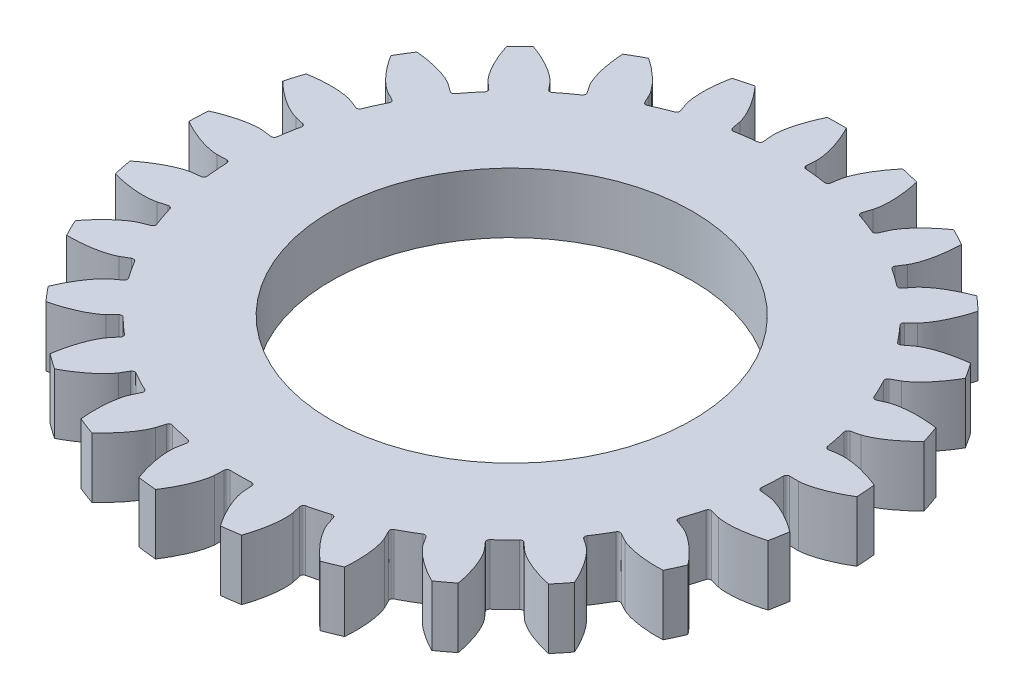
from build123d import *

# Parameters (mm, degrees)
SKETCH3_R               = 27.365
BOSS_EXTRUDE2_DEPTH     = 5
CUT_EXTRUDE1_DEPTH      = 5
FILLET1_R               = 0.253365
FILLET1_OF_MIRROR2_R    = 0.253365
CUT_EXTRUDE2_DEPTH      = 1.0000001
CUT_EXTRUDE2_DEPTH_BACK = 6.0000001
SKETCH6_R               = 15
CUT_EXTRUDE3_DEPTH      = 6.0000001


with BuildPart() as part:
    # Sketch3 → Boss-Extrude2 (new body)
    with BuildSketch(Plane(origin=(0, 0, 0), x_dir=(1, 0, 0), z_dir=(0, 1, 0))):
        Circle(SKETCH3_R)
    extrude(amount=-BOSS_EXTRUDE2_DEPTH)

    # Sketch4 → Cut-Extrude1 (cut)
    with BuildSketch(Plane(origin=(0, 0, 0), x_dir=(1, 0, 0), z_dir=(0, 1, 0))):
        with BuildLine():
            Line((23.808522087, 0), (22.80285, 0))
            ThreePointArc((22.80285, 0), (22.795921147, -0.5620918), (22.775138798, -1.123842007))
            Line((22.775138798, -1.123842007), (23.77958874, -1.173406713))
            ThreePointArc((23.77958874, -1.173406713), (23.801287651, -0.586881686), (23.808522087, 0))
        make_face()
        with BuildLine():
            add(Edge.make_bspline(
                [(23.808522087, 0), (23.826127738, 0), (23.875493591, 0.001153826), (23.968710388, 0.007885238), (24.12033093, 0.025327574), (24.400623176, 0.071497926), (24.734861734, 0.149847288), (25.0216111, 0.235022861), (25.248624765, 0.312256933), (25.334182097, 0.342709373)],
                knots=[0, 0, 0, 0, 0, 0.005376748, 0.015083688, 0.02853182, 0.046610139, 0.092110525, 0.119851432, 0.119851432, 0.119851432, 0.119851432, 0.119851432], degree=4))
            ThreePointArc((23.808522087, 0), (23.801287651, -0.586881686), (23.77958874, -1.173406713))
            Line((23.77958874, -1.173406713), (25.305709775, -1.248713342))
            ThreePointArc((25.305709775, -1.248713342), (25.328801274, -0.624546445), (25.3365, 0))
            ThreePointArc((25.3365, 0), (25.335920518, 0.171358606), (25.334182097, 0.342709373))
        make_face()
        with BuildLine():
            add(Edge.make_bspline(
                [(25.334182097, 0.342709373), (25.417426792, 0.372338675), (25.584260581, 0.434295585), (25.83262126, 0.533914927), (26.159196991, 0.67860072), (26.481919478, 0.83452889), (26.817171703, 1.009474652), (27.068710359, 1.150910221), (27.240106641, 1.251913602), (27.333700787, 1.308444232)],
                knots=[0.119851432, 0.119851432, 0.119851432, 0.119851432, 0.119851432, 0.146842495, 0.174208853, 0.201574955, 0.228941013, 0.256307345, 0.289707973, 0.289707973, 0.289707973, 0.289707973, 0.289707973], degree=4))
            ThreePointArc((25.334182097, 0.342709373), (25.335920518, 0.171358606), (25.3365, 0))
            ThreePointArc((25.3365, 0), (25.328801274, -0.624546445), (25.305709775, -1.248713342))
            Line((25.305709775, -1.248713342), (27.331744637, -1.348688279))
            ThreePointArc((27.331744637, -1.348688279), (27.364992584, -0.02014578), (27.333700787, 1.308444232))
        make_face()
    cut_extrude1 = extrude(amount=-CUT_EXTRUDE1_DEPTH, mode=Mode.SUBTRACT)

    # Fillet1
    fillet1_edges = [part.edges().sort_by_distance(p)[0] for p in [
        (22.80285, -2.5, 0),
    ]]
    fillet(fillet1_edges, radius=FILLET1_R)

    # Mirror2: Cut-Extrude1 across plane
    add(cut_extrude1.mirror(Plane(origin=(0, 0, 0), x_dir=(0.998784748, 0, 0.049285155), z_dir=(0.049285155, 0, -0.998784748))), mode=Mode.SUBTRACT)

    # Fillet1 of Mirror2
    fillet1_of_mirror2_edges = [part.edges().sort_by_distance(p)[0] for p in [
        (22.692072544, -2.5, 2.244952513),
    ]]
    fillet(fillet1_of_mirror2_edges, radius=FILLET1_OF_MIRROR2_R)

    # Sketch5 → Cut-Extrude2 (cut, two sides)
    with BuildSketch(Plane(origin=(0, 0, 0), x_dir=(1, 0, 0), z_dir=(0, 1, 0))) as cut_extrude2_sk:
        with BuildLine():
            ThreePointArc((-27.359092388, 0.568584829), (-27.28526113, -2.087522465), (-26.954174845, -4.723947863))
            add(Edge.make_bspline(
                [(-23.620784779, -2.983999059), (-23.638251604, -2.986205633), (-23.68708358, -2.993537543), (-23.778721665, -3.011899038), (-23.92696053, -3.048206929), (-24.199255908, -3.129143147), (-24.603939354, -3.279584024), (-25.037594793, -3.479346919), (-25.484225761, -3.720479602), (-25.867872687, -3.951866497), (-26.260239061, -4.206557346), (-26.568269996, -4.426083737), (-26.79812866, -4.600569009), (-26.954174845, -4.723947863)],
                knots=[0, 0, 0, 0, 0, 0.005376748, 0.015083688, 0.02853182, 0.046610139, 0.092110525, 0.146842495, 0.174208853, 0.201574955, 0.228941013, 0.289707973, 0.289707973, 0.289707973, 0.289707973, 0.289707973], degree=4))
            Line((-23.620784779, -2.983999059), (-22.873028678, -2.889535496))
            ThreePointArc((-22.873028678, -2.889535496), (-22.705442381, -2.79455521), (-22.653082813, -2.609177494))
            ThreePointArc((-22.653082813, -2.609177494), (-22.736404779, -1.739501613), (-22.78635133, -0.867272268))
            ThreePointArc((-22.78635133, -0.867272268), (-22.866301945, -0.692017251), (-23.046386572, -0.623636339))
            Line((-23.046386572, -0.623636339), (-23.799810021, -0.644024014))
            add(Edge.make_bspline(
                [(-23.799810021, -0.644024014), (-23.81740923, -0.644500249), (-23.86678823, -0.644682199), (-23.960153002, -0.640474778), (-24.112189881, -0.627140182), (-24.393628477, -0.588568672), (-24.816487668, -0.501440873), (-25.275484731, -0.369972436), (-25.753599653, -0.199589591), (-26.16798101, -0.02925771), (-26.594525428, 0.162780461), (-26.93236659, 0.332892903), (-27.186093453, 0.470380338), (-27.359092388, 0.568584829)],
                knots=[0, 0, 0, 0, 0, 0.005376748, 0.015083688, 0.02853182, 0.046610139, 0.092110525, 0.146842495, 0.174208853, 0.201574955, 0.228941013, 0.289707973, 0.289707973, 0.289707973, 0.289707973, 0.289707973], degree=4))
        make_face()
        with BuildLine():
            ThreePointArc((-26.358154894, 7.35465129), (-26.947190204, 4.763629404), (-27.282157938, 2.127694346))
            add(Edge.make_bspline(
                [(-23.620784779, 2.983999059), (-23.638251604, 2.986205633), (-23.687372806, 2.991248087), (-23.78069823, 2.996252917), (-23.933309303, 2.997951211), (-24.217178041, 2.98727486), (-24.646560737, 2.942201041), (-25.116271105, 2.856559786), (-25.608837599, 2.734075335), (-26.037975132, 2.605366996), (-26.481353633, 2.456255278), (-26.834301203, 2.32022989), (-27.100331158, 2.208389919), (-27.282157938, 2.127694346)],
                knots=[0, 0, 0, 0, 0, 0.005376748, 0.015083688, 0.02853182, 0.046610139, 0.092110525, 0.146842495, 0.174208853, 0.201574955, 0.228941013, 0.289707973, 0.289707973, 0.289707973, 0.289707973, 0.289707973], degree=4))
            Line((-23.620784779, 2.983999059), (-22.873028678, 2.889535496))
            ThreePointArc((-22.873028678, 2.889535496), (-22.687086776, 2.939854785), (-22.590270617, 3.106387224))
            ThreePointArc((-22.590270617, 3.106387224), (-22.454695273, 3.969461968), (-22.286158044, 4.826709826))
            ThreePointArc((-22.286158044, 4.826709826), (-22.320012713, 5.016341794), (-22.477434009, 5.12735962))
            Line((-22.477434009, 5.12735962), (-23.212257483, 5.294981254))
            add(Edge.make_bspline(
                [(-23.212257483, 5.294981254), (-23.229422216, 5.298896725), (-23.277295133, 5.31100055), (-23.366680336, 5.338294661), (-23.510624518, 5.389020361), (-23.773628858, 5.496371009), (-24.161535347, 5.685922332), (-24.573417304, 5.927408374), (-24.994138875, 6.211340675), (-25.353141864, 6.47937372), (-25.718527653, 6.771455942), (-26.00344967, 7.020241668), (-26.215013502, 7.216508988), (-26.358154894, 7.35465129)],
                knots=[0, 0, 0, 0, 0, 0.005376748, 0.015083688, 0.02853182, 0.046610139, 0.092110525, 0.146842495, 0.174208853, 0.201574955, 0.228941013, 0.289707973, 0.289707973, 0.289707973, 0.289707973, 0.289707973], degree=4))
        make_face()
        with BuildLine():
            add(Edge.make_bspline(
                [(-21.16619344, 10.901283375), (-21.181845172, 10.90934453), (-21.225203975, 10.932973602), (-21.304993208, 10.981639414), (-21.43180015, 11.066568935), (-21.659844705, 11.235953485), (-21.988424901, 11.516018126), (-22.327311692, 11.852348317), (-22.66420443, 12.231989562), (-22.945271572, 12.580882269), (-23.2265402, 12.954655942), (-23.440640373, 13.266482831), (-23.596747841, 13.509197837), (-23.701037589, 13.678597962)],
                knots=[0, 0, 0, 0, 0, 0.005376748, 0.015083688, 0.02853182, 0.046610139, 0.092110525, 0.146842495, 0.174208853, 0.201574955, 0.228941013, 0.289707973, 0.289707973, 0.289707973, 0.289707973, 0.289707973], degree=4))
            ThreePointArc((-23.701037589, 13.678597962), (-24.915928213, 11.315464918), (-25.895902711, 8.845645695))
            add(Edge.make_bspline(
                [(-22.136604, 8.764501543), (-22.152973321, 8.770982616), (-22.199297282, 8.788082598), (-22.288446065, 8.816139281), (-22.435840233, 8.855737051), (-22.713445812, 8.915991402), (-23.140548064, 8.979116794), (-23.616799731, 9.012978335), (-24.124351988, 9.016838263), (-24.572015839, 8.998895698), (-25.038547365, 8.964732348), (-25.414234576, 8.92075494), (-25.699720181, 8.878587587), (-25.895902711, 8.845645695)],
                knots=[0, 0, 0, 0, 0, 0.005376748, 0.015083688, 0.02853182, 0.046610139, 0.092110525, 0.146842495, 0.174208853, 0.201574955, 0.228941013, 0.289707973, 0.289707973, 0.289707973, 0.289707973, 0.289707973], degree=4))
            Line((-22.136604, 8.764501543), (-21.435832165, 8.487046346))
            ThreePointArc((-21.435832165, 8.487046346), (-21.243218071, 8.489542891), (-21.108028637, 8.626766208))
            ThreePointArc((-21.108028637, 8.626766208), (-20.762074681, 9.429009655), (-20.385643486, 10.217411991))
            ThreePointArc((-20.385643486, 10.217411991), (-20.371274996, 10.409505636), (-20.496141601, 10.556184716))
            Line((-20.496141601, 10.556184716), (-21.16619344, 10.901283375))
        make_face()
        with BuildLine():
            add(Edge.make_bspline(
                [(-17.790179618, 15.82261777), (-17.803334895, 15.834318097), (-17.83945519, 15.867987713), (-17.904635003, 15.934967375), (-18.006336959, 16.048764283), (-18.185092849, 16.26953968), (-18.433700851, 16.622520148), (-18.678298972, 17.032561625), (-18.910194667, 17.484057559), (-19.09566548, 17.891887716), (-19.275143805, 18.323867265), (-19.404969433, 18.679142087), (-19.495811731, 18.953054104), (-19.554696927, 19.143068017)],
                knots=[0, 0, 0, 0, 0, 0.005376748, 0.015083688, 0.02853182, 0.046610139, 0.092110525, 0.146842495, 0.174208853, 0.201574955, 0.228941013, 0.289707973, 0.289707973, 0.289707973, 0.289707973, 0.289707973], degree=4))
            ThreePointArc((-19.554696927, 19.143068017), (-21.319106817, 17.156308155), (-22.882512679, 15.007792593))
            add(Edge.make_bspline(
                [(-19.261498979, 13.994298161), (-19.27574225, 14.004646504), (-19.316358266, 14.032729559), (-19.395728864, 14.082075191), (-19.528644807, 14.157084363), (-19.782544249, 14.284483413), (-20.180529652, 14.451841615), (-20.633397974, 14.603078307), (-21.124044618, 14.733040082), (-21.56210642, 14.826990688), (-22.022477081, 14.909922316), (-22.397298124, 14.960756149), (-22.684301267, 14.990910943), (-22.882512679, 15.007792593)],
                knots=[0, 0, 0, 0, 0, 0.005376748, 0.015083688, 0.02853182, 0.046610139, 0.092110525, 0.146842495, 0.174208853, 0.201574955, 0.228941013, 0.289707973, 0.289707973, 0.289707973, 0.289707973, 0.289707973], degree=4))
            Line((-19.261498979, 13.994298161), (-18.651743482, 13.551284861))
            ThreePointArc((-18.651743482, 13.551284861), (-18.464559848, 13.505801795), (-18.299491587, 13.605093744))
            ThreePointArc((-18.299491587, 13.605093744), (-17.764896579, 14.296097987), (-17.204223974, 14.966116583))
            ThreePointArc((-17.204223974, 14.966116583), (-17.142535149, 15.148601954), (-17.227001237, 15.321725904))
            Line((-17.227001237, 15.321725904), (-17.790179618, 15.82261777))
        make_face()
        with BuildLine():
            add(Edge.make_bspline(
                [(-13.296343384, 19.749758899), (-13.306175611, 19.764363223), (-13.332787827, 19.805957798), (-13.379262731, 19.887042731), (-13.449469393, 20.022556748), (-13.56770473, 20.280850862), (-13.720719581, 20.684568095), (-13.855660035, 21.142556445), (-13.967987827, 21.637537918), (-14.046208497, 22.078680056), (-14.112619235, 22.541722617), (-14.150012897, 22.918122149), (-14.169882068, 23.206020276), (-14.179662739, 23.404708706)],
                knots=[0, 0, 0, 0, 0, 0.005376748, 0.015083688, 0.02853182, 0.046610139, 0.092110525, 0.146842495, 0.174208853, 0.201574955, 0.228941013, 0.289707973, 0.289707973, 0.289707973, 0.289707973, 0.289707973], degree=4))
            ThreePointArc((-14.179662739, 23.404708706), (-16.382727534, 21.919157455), (-18.431330218, 20.226944687))
            add(Edge.make_bspline(
                [(-15.176123138, 18.344781559), (-15.187345403, 18.358346946), (-15.21970142, 18.395648513), (-15.284306685, 18.463182526), (-15.394392807, 18.568889998), (-15.608632676, 18.755428796), (-15.952494343, 19.016504078), (-16.353523938, 19.275613163), (-16.796435837, 19.523510809), (-17.197370556, 19.723451324), (-17.622653568, 19.918267029), (-17.973057059, 20.060718027), (-18.243544279, 20.161300232), (-18.431330218, 20.226944687)],
                knots=[0, 0, 0, 0, 0, 0.005376748, 0.015083688, 0.02853182, 0.046610139, 0.092110525, 0.146842495, 0.174208853, 0.201574955, 0.228941013, 0.289707973, 0.289707973, 0.289707973, 0.289707973, 0.289707973], degree=4))
            Line((-15.176123138, 18.344781559), (-14.695697159, 17.76404631))
            ThreePointArc((-14.695697159, 17.76404631), (-14.525705422, 17.673441501), (-14.341130181, 17.728563204))
            ThreePointArc((-14.341130181, 17.728563204), (-13.65148469, 18.264909906), (-12.941799797, 18.774445028))
            ThreePointArc((-12.941799797, 18.774445028), (-12.836666774, 18.9358559), (-12.875425029, 19.124546704))
            Line((-12.875425029, 19.124546704), (-13.296343384, 19.749758899))
        make_face()
        with BuildLine():
            add(Edge.make_bspline(
                [(-7.967048994, 22.435950042), (-7.972940376, 22.452540719), (-7.98837237, 22.499446714), (-8.013222177, 22.589542053), (-8.047522202, 22.738258334), (-8.097807824, 23.017841597), (-8.145615039, 23.446928557), (-8.162419019, 23.924086686), (-8.148120941, 24.431452193), (-8.114176576, 24.878187728), (-8.063346896, 25.343198635), (-8.00595901, 25.717072309), (-7.953606603, 26.000866849), (-7.913668192, 26.19574547)],
                knots=[0, 0, 0, 0, 0, 0.005376748, 0.015083688, 0.02853182, 0.046610139, 0.092110525, 0.146842495, 0.174208853, 0.201574955, 0.228941013, 0.289707973, 0.289707973, 0.289707973, 0.289707973, 0.289707973], degree=4))
            ThreePointArc((-7.913668192, 26.19574547), (-10.416961228, 25.304745479), (-12.822039494, 24.175163458))
            add(Edge.make_bspline(
                [(-10.137175667, 21.542594863), (-10.144671789, 21.558524933), (-10.16673476, 21.602701217), (-10.212515305, 21.684180201), (-10.29285449, 21.813943984), (-10.453973307, 22.047901611), (-10.722105145, 22.386289652), (-11.046097849, 22.736990353), (-11.413445218, 23.087247548), (-11.752060652, 23.380614975), (-12.115533921, 23.675073771), (-12.419502719, 23.900191213), (-12.656478308, 24.064880879), (-12.822039494, 24.175163458)],
                knots=[0, 0, 0, 0, 0, 0.005376748, 0.015083688, 0.02853182, 0.046610139, 0.092110525, 0.146842495, 0.174208853, 0.201574955, 0.228941013, 0.289707973, 0.289707973, 0.289707973, 0.289707973, 0.289707973], degree=4))
            Line((-10.137175667, 21.542594863), (-9.816266137, 20.860627398))
            ThreePointArc((-9.816266137, 20.860627398), (-9.674147503, 20.73059388), (-9.481662822, 20.738081836))
            ThreePointArc((-9.481662822, 20.738081836), (-8.680299812, 21.086070362), (-7.866194743, 21.403106045))
            ThreePointArc((-7.866194743, 21.403106045), (-7.724223415, 21.533300378), (-7.714838513, 21.725701899))
            Line((-7.714838513, 21.725701899), (-7.967048994, 22.435950042))
        make_face()
        with BuildLine():
            add(Edge.make_bspline(
                [(-2.137155615, 23.71240793), (-2.138735974, 23.729942508), (-2.142018098, 23.779212645), (-2.143681402, 23.872657369), (-2.139919594, 24.025231525), (-2.119095871, 24.30853669), (-2.058691547, 24.736032265), (-1.956303198, 25.202378575), (-1.816277649, 25.690248473), (-1.672301099, 26.11450737), (-1.507424817, 26.552268277), (-1.358861276, 26.900124235), (-1.237576783, 27.161983333), (-1.150428768, 27.340807206)],
                knots=[0, 0, 0, 0, 0, 0.005376748, 0.015083688, 0.02853182, 0.046610139, 0.092110525, 0.146842495, 0.174208853, 0.201574955, 0.228941013, 0.289707973, 0.289707973, 0.289707973, 0.289707973, 0.289707973], degree=4))
            ThreePointArc((-1.150428768, 27.340807206), (-3.796658938, 27.10034328), (-6.407092873, 26.604367798))
            add(Edge.make_bspline(
                [(-4.461272167, 23.386807704), (-4.464571137, 23.404101511), (-4.474954764, 23.452376754), (-4.49903403, 23.542681084), (-4.544578271, 23.688347642), (-4.642452349, 23.95502368), (-4.818006648, 24.349462315), (-5.044604808, 24.769718819), (-5.313305861, 25.200327616), (-5.568325556, 25.568688599), (-5.847150719, 25.944288556), (-6.085585347, 26.237927487), (-6.274159258, 26.456376557), (-6.407092873, 26.604367798)],
                knots=[0, 0, 0, 0, 0, 0.005376748, 0.015083688, 0.02853182, 0.046610139, 0.092110525, 0.146842495, 0.174208853, 0.201574955, 0.228941013, 0.289707973, 0.289707973, 0.289707973, 0.289707973, 0.289707973], degree=4))
            Line((-4.461272167, 23.386807704), (-4.320043012, 22.646458546))
            ThreePointArc((-4.320043012, 22.646458546), (-4.214727317, 22.485166803), (-4.026427717, 22.444550518))
            ThreePointArc((-4.026427717, 22.444550518), (-3.163699772, 22.582315468), (-2.296327743, 22.686931194))
            ThreePointArc((-2.296327743, 22.686931194), (-2.126438692, 22.777728399), (-2.069500321, 22.961751343))
            Line((-2.069500321, 22.961751343), (-2.137155615, 23.71240793))
        make_face()
        with BuildLine():
            add(Edge.make_bspline(
                [(3.827023111, 23.498928019), (3.829853074, 23.516304736), (3.838927049, 23.564843192), (3.860554758, 23.655765825), (3.902142032, 23.802611059), (3.992766669, 24.071837023), (4.157587106, 24.470880094), (4.372734349, 24.897112329), (4.629689047, 25.33483196), (4.874651206, 25.709956472), (5.143214307, 26.092961251), (5.373618711, 26.392942423), (5.556214538, 26.61641251), (5.685096326, 26.767945472)],
                knots=[0, 0, 0, 0, 0, 0.005376748, 0.015083688, 0.02853182, 0.046610139, 0.092110525, 0.146842495, 0.174208853, 0.201574955, 0.228941013, 0.289707973, 0.289707973, 0.289707973, 0.289707973, 0.289707973], degree=4))
            ThreePointArc((5.685096326, 26.767945472), (3.062201397, 27.193126845), (0.410434957, 27.361921865))
            add(Edge.make_bspline(
                [(1.494949471, 23.761541407), (1.496054939, 23.779112317), (1.498003097, 23.828453208), (1.497138099, 23.921908731), (1.489250514, 24.074325299), (1.460770965, 24.356963512), (1.388824926, 24.782668711), (1.273859307, 25.246074754), (1.120688044, 25.729978418), (0.965287913, 26.150187483), (0.788630466, 26.583328276), (0.630711733, 26.92703828), (0.502388294, 27.185520795), (0.410434957, 27.361921865)],
                knots=[0, 0, 0, 0, 0, 0.005376748, 0.015083688, 0.02853182, 0.046610139, 0.092110525, 0.146842495, 0.174208853, 0.201574955, 0.228941013, 0.289707973, 0.289707973, 0.289707973, 0.289707973, 0.289707973], degree=4))
            Line((1.494949471, 23.761541407), (1.447624304, 23.009329416))
            ThreePointArc((1.447624304, 23.009329416), (1.509519687, 22.826914002), (1.68180265, 22.740745546))
            ThreePointArc((1.68180265, 22.740745546), (2.551687159, 22.65963064), (3.417825975, 22.54525302))
            ThreePointArc((3.417825975, 22.54525302), (3.604957995, 22.590947974), (3.705872188, 22.755029502))
            Line((3.705872188, 22.755029502), (3.827023111, 23.498928019))
        make_face()
        with BuildLine():
            add(Edge.make_bspline(
                [(9.5507359, 21.808924038), (9.557798368, 21.82505105), (9.578658291, 21.869807976), (9.622218065, 21.952495515), (9.699017723, 22.084385001), (9.853748995, 22.322615306), (10.112629272, 22.668132528), (10.427016914, 23.027468951), (10.784755354, 23.387534779), (11.115311249, 23.689954453), (11.470686361, 23.994137505), (11.768454471, 24.227394973), (12.000888465, 24.3984346), (12.16340591, 24.513155278)],
                knots=[0, 0, 0, 0, 0, 0.005376748, 0.015083688, 0.02853182, 0.046610139, 0.092110525, 0.146842495, 0.174208853, 0.201574955, 0.228941013, 0.289707973, 0.289707973, 0.289707973, 0.289707973, 0.289707973], degree=4))
            ThreePointArc((12.16340591, 24.513155278), (9.728652356, 25.577266241), (7.202173649, 26.400225751))
            add(Edge.make_bspline(
                [(7.357237936, 22.643250074), (7.362678381, 22.659994043), (7.376835915, 22.707300312), (7.399239536, 22.798034874), (7.429504213, 22.947624557), (7.472208666, 23.228465747), (7.508391523, 23.658688887), (7.512282156, 24.136126964), (7.484264998, 24.642920049), (7.438248793, 25.088573914), (7.3748591, 25.552039713), (7.307378876, 25.924224227), (7.247368941, 26.206498781), (7.202173649, 26.400225751)],
                knots=[0, 0, 0, 0, 0, 0.005376748, 0.015083688, 0.02853182, 0.046610139, 0.092110525, 0.146842495, 0.174208853, 0.201574955, 0.228941013, 0.289707973, 0.289707973, 0.289707973, 0.289707973, 0.289707973], degree=4))
            Line((7.357237936, 22.643250074), (7.124332061, 21.926439496))
            ThreePointArc((7.124332061, 21.926439496), (7.138918018, 21.734362242), (7.284359171, 21.608055896))
            ThreePointArc((7.284359171, 21.608055896), (8.106742202, 21.313157884), (8.917225117, 20.986973682))
            ThreePointArc((8.917225117, 20.986973682), (9.109841914, 20.984695205), (9.248391118, 21.11852547))
            Line((9.248391118, 21.11852547), (9.5507359, 21.808924038))
        make_face()
        with BuildLine():
            add(Edge.make_bspline(
                [(14.674340827, 18.748585153), (14.68519204, 18.76244914), (14.716527205, 18.800612293), (14.779282023, 18.869869176), (14.88646846, 18.978515813), (15.095584032, 19.170781572), (15.432257748, 19.441062829), (15.826131659, 19.710925009), (16.262175818, 19.970712776), (16.657555406, 20.181425471), (17.077413005, 20.387673857), (17.423834955, 20.539551194), (17.691502434, 20.647413313), (17.877443966, 20.718113385)],
                knots=[0, 0, 0, 0, 0, 0.005376748, 0.015083688, 0.02853182, 0.046610139, 0.092110525, 0.146842495, 0.174208853, 0.201574955, 0.228941013, 0.289707973, 0.289707973, 0.289707973, 0.289707973, 0.289707973], degree=4))
            ThreePointArc((17.877443966, 20.718113385), (15.783816307, 22.354291932), (13.541373283, 23.779706361))
            add(Edge.make_bspline(
                [(12.757244083, 20.102200063), (12.766677663, 20.117065006), (12.792155002, 20.159364225), (12.83641954, 20.24167664), (12.902934838, 20.37904017), (13.014140017, 20.640438052), (13.156178266, 21.04814663), (13.278680689, 21.50961755), (13.377578057, 22.007456383), (13.443837145, 22.450552977), (13.497698213, 22.915222521), (13.524896529, 23.292495824), (13.536970743, 23.580826067), (13.541373283, 23.779706361)],
                knots=[0, 0, 0, 0, 0, 0.005376748, 0.015083688, 0.02853182, 0.046610139, 0.092110525, 0.146842495, 0.174208853, 0.201574955, 0.228941013, 0.289707973, 0.289707973, 0.289707973, 0.289707973, 0.289707973], degree=4))
            Line((12.757244083, 20.102200063), (12.353391833, 19.465830743))
            ThreePointArc((12.353391833, 19.465830743), (12.319751874, 19.276160569), (12.429212615, 19.117652625))
            ThreePointArc((12.429212615, 19.117652625), (13.152420818, 18.627501033), (13.856322209, 18.110005604))
            ThreePointArc((13.856322209, 18.110005604), (14.042320961, 18.059896859), (14.20979962, 18.155066815))
            Line((14.20979962, 18.155066815), (14.674340827, 18.748585153))
        make_face()
        with BuildLine():
            add(Edge.make_bspline(
                [(18.875902952, 14.510203709), (18.889861087, 14.520933547), (18.92970259, 14.550104996), (19.007709338, 14.601579557), (19.138547635, 14.680156678), (19.388908007, 14.814377126), (19.782220714, 14.992439652), (20.230832347, 15.155871158), (20.717783968, 15.299057441), (21.153144095, 15.404823304), (21.611102983, 15.500177679), (21.984411809, 15.561131875), (22.27049424, 15.599039112), (22.46817647, 15.621276233)],
                knots=[0, 0, 0, 0, 0, 0.005376748, 0.015083688, 0.02853182, 0.046610139, 0.092110525, 0.146842495, 0.174208853, 0.201574955, 0.228941013, 0.289707973, 0.289707973, 0.289707973, 0.289707973, 0.289707973], degree=4))
            ThreePointArc((22.46817647, 15.621276233), (20.847225032, 17.726715248), (19.029718633, 19.665020564))
            add(Edge.make_bspline(
                [(17.355665666, 16.298054891), (17.368499634, 16.310106789), (17.403695944, 16.344741144), (17.467040096, 16.41345942), (17.565626614, 16.529965739), (17.738345087, 16.755495723), (17.977313943, 17.11507191), (18.210730879, 17.531579759), (18.430328687, 17.989183294), (18.604699766, 18.401881229), (18.772427306, 18.838557622), (18.892595192, 19.197214244), (18.975994888, 19.473483327), (19.029718633, 19.665020564)],
                knots=[0, 0, 0, 0, 0, 0.005376748, 0.015083688, 0.02853182, 0.046610139, 0.092110525, 0.146842495, 0.174208853, 0.201574955, 0.228941013, 0.289707973, 0.289707973, 0.289707973, 0.289707973, 0.289707973], degree=4))
            Line((17.355665666, 16.298054891), (16.806242563, 15.782112255))
            ThreePointArc((16.806242563, 15.782112255), (16.726490412, 15.606766835), (16.793092919, 15.42601693))
            ThreePointArc((16.793092919, 15.42601693), (17.371684463, 14.771409786), (17.924775617, 14.095119269))
            ThreePointArc((17.924775617, 14.095119269), (18.092469338, 14.000328774), (18.278354153, 14.050858542))
            Line((18.278354153, 14.050858542), (18.875902952, 14.510203709))
        make_face()
        with BuildLine():
            add(Edge.make_bspline(
                [(21.891422674, 9.360092802), (21.907610691, 9.367014296), (21.953455144, 9.38536109), (22.041812369, 9.415818995), (22.188081476, 9.459389309), (22.463955584, 9.527130883), (22.889193999, 9.601786354), (23.364355435, 9.648518182), (23.871617556, 9.666106061), (24.319602945, 9.660279435), (24.786887881, 9.638748332), (25.163627215, 9.60494941), (25.450148987, 9.570519914), (25.647150813, 9.542896843)],
                knots=[0, 0, 0, 0, 0, 0.005376748, 0.015083688, 0.02853182, 0.046610139, 0.092110525, 0.146842495, 0.174208853, 0.201574955, 0.228941013, 0.289707973, 0.289707973, 0.289707973, 0.289707973, 0.289707973], degree=4))
            ThreePointArc((25.647150813, 9.542896843), (24.600725937, 11.98530385), (23.322356774, 14.314709202))
            add(Edge.make_bspline(
                [(20.863566946, 11.46984299), (20.878994896, 11.478324577), (20.921698663, 11.503117864), (21.000142282, 11.553924179), (21.124605467, 11.642252769), (21.347984698, 11.817743976), (21.66886887, 12.106594278), (21.998533874, 12.451968335), (22.325033984, 12.840583659), (22.596560678, 13.196951606), (22.867615751, 13.578196864), (23.073202617, 13.895701091), (23.222687486, 14.142550012), (23.322356774, 14.314709202)],
                knots=[0, 0, 0, 0, 0, 0.005376748, 0.015083688, 0.02853182, 0.046610139, 0.092110525, 0.146842495, 0.174208853, 0.201574955, 0.228941013, 0.289707973, 0.289707973, 0.289707973, 0.289707973, 0.289707973], degree=4))
            Line((20.863566946, 11.46984299), (20.203095264, 11.10674561))
            ThreePointArc((20.203095264, 11.10674561), (20.082242041, 10.956742543), (20.101801435, 10.765107859))
            ThreePointArc((20.101801435, 10.765107859), (20.499421284, 9.987176536), (20.86694945, 9.194584753))
            ThreePointArc((20.86694945, 9.194584753), (21.005801327, 9.061068543), (21.198412471, 9.063783151))
            Line((21.198412471, 9.063783151), (21.891422674, 9.360092802))
        make_face()
        with BuildLine():
            add(Edge.make_bspline(
                [(23.531423798, 3.62185284), (23.548824544, 3.624531086), (23.597791372, 3.630900431), (23.690947264, 3.638427896), (23.843456555, 3.644253721), (24.127510215, 3.641259967), (24.557955044, 3.607817507), (25.029810143, 3.534913324), (25.525509619, 3.425797688), (25.957971701, 3.30874468), (26.405221453, 3.171680978), (26.761719379, 3.045252649), (27.030677275, 2.940649752), (27.214620348, 2.864902149)],
                knots=[0, 0, 0, 0, 0, 0.005376748, 0.015083688, 0.02853182, 0.046610139, 0.092110525, 0.146842495, 0.174208853, 0.201574955, 0.228941013, 0.289707973, 0.289707973, 0.289707973, 0.289707973, 0.289707973], degree=4))
            ThreePointArc((27.214620348, 2.864902149), (26.808472756, 5.490811733), (26.149565465, 8.064952015))
            add(Edge.make_bspline(
                [(23.060533584, 5.920938671), (23.077586122, 5.925317019), (23.125114111, 5.938711384), (23.213728297, 5.968413391), (23.356247668, 6.023014239), (23.616251918, 6.137439911), (23.998889073, 6.337414802), (24.40408808, 6.589953946), (24.81697529, 6.885162929), (25.168596578, 7.162808978), (25.525947798, 7.46466806), (25.804035865, 7.721069933), (26.010213222, 7.922988266), (26.149565465, 8.064952015)],
                knots=[0, 0, 0, 0, 0, 0.005376748, 0.015083688, 0.02853182, 0.046610139, 0.092110525, 0.146842495, 0.174208853, 0.201574955, 0.228941013, 0.289707973, 0.289707973, 0.289707973, 0.289707973, 0.289707973], degree=4))
            Line((23.060533584, 5.920938671), (22.330513188, 5.733501291))
            ThreePointArc((22.330513188, 5.733501291), (22.176152545, 5.61826582), (22.147439837, 5.427787469))
            ThreePointArc((22.147439837, 5.427787469), (22.339104074, 4.575412254), (22.497976106, 3.716320661))
            ThreePointArc((22.497976106, 3.716320661), (22.599261565, 3.552468051), (22.786496571, 3.507196931))
            Line((22.786496571, 3.507196931), (23.531423798, 3.62185284))
        make_face()
        with BuildLine():
            ThreePointArc((25.228530742, -10.600210451), (26.137662484, -8.103445247), (26.800359162, -5.530277914))
            add(Edge.make_bspline(
                [(23.060533584, -5.920938671), (23.077586122, -5.925317019), (23.125688001, -5.936476231), (23.217650255, -5.953138373), (23.368845092, -5.973950515), (23.651813541, -5.998936537), (24.083459673, -6.00803406), (24.56019993, -5.981938432), (25.064233763, -5.922154758), (25.506118851, -5.848246518), (25.964689834, -5.755880651), (26.331902808, -5.665163925), (26.609852303, -5.58754824), (26.800359162, -5.530277914)],
                knots=[0, 0, 0, 0, 0, 0.005376748, 0.015083688, 0.02853182, 0.046610139, 0.092110525, 0.146842495, 0.174208853, 0.201574955, 0.228941013, 0.289707973, 0.289707973, 0.289707973, 0.289707973, 0.289707973], degree=4))
            Line((23.060533584, -5.920938671), (22.330513188, -5.733501291))
            ThreePointArc((22.330513188, -5.733501291), (22.139730814, -5.760119097), (22.02280603, -5.913204096))
            ThreePointArc((22.02280603, -5.913204096), (21.78012779, -6.752481142), (21.505477882, -7.581846029))
            ThreePointArc((21.505477882, -7.581846029), (21.515298409, -7.774225807), (21.657564167, -7.904098344))
            Line((21.657564167, -7.904098344), (22.365584778, -8.162496034))
            add(Edge.make_bspline(
                [(22.365584778, -8.162496034), (22.382123422, -8.168531942), (22.428101836, -8.186540392), (22.513361351, -8.224822218), (22.649812874, -8.293188919), (22.897288742, -8.43265626), (23.258379393, -8.66933049), (23.63674731, -8.960534839), (24.018565214, -9.294958644), (24.341143908, -9.605873173), (24.667040912, -9.941447222), (24.918535113, -10.223981397), (25.103831884, -10.445217069), (25.228530742, -10.600210451)],
                knots=[0, 0, 0, 0, 0, 0.005376748, 0.015083688, 0.02853182, 0.046610139, 0.092110525, 0.146842495, 0.174208853, 0.201574955, 0.228941013, 0.289707973, 0.289707973, 0.289707973, 0.289707973, 0.289707973], degree=4))
        make_face()
        with BuildLine():
            ThreePointArc((21.778981994, -16.568619988), (23.292243459, -14.363656207), (24.583052406, -12.02151236))
            add(Edge.make_bspline(
                [(20.863566946, -11.46984299), (20.878994896, -11.478324577), (20.922810383, -11.501095653), (21.007739767, -11.540104406), (21.149008771, -11.597863324), (21.416873475, -11.692435755), (21.832696189, -11.808593491), (22.300948493, -11.901878185), (22.804014771, -11.969320843), (23.250397458, -12.007626918), (23.717532047, -12.032204861), (24.095768683, -12.035660321), (24.384288119, -12.029606304), (24.583052406, -12.02151236)],
                knots=[0, 0, 0, 0, 0, 0.005376748, 0.015083688, 0.02853182, 0.046610139, 0.092110525, 0.146842495, 0.174208853, 0.201574955, 0.228941013, 0.289707973, 0.289707973, 0.289707973, 0.289707973, 0.289707973], degree=4))
            Line((20.863566946, -11.46984299), (20.203095264, -11.10674561))
            ThreePointArc((20.203095264, -11.10674561), (20.01168709, -11.085081522), (19.860365022, -11.204279063))
            ThreePointArc((19.860365022, -11.204279063), (19.416591251, -11.956837052), (18.944315315, -12.691843262))
            ThreePointArc((18.944315315, -12.691843262), (18.905984406, -12.880621341), (19.011482638, -13.041793749))
            Line((19.011482638, -13.041793749), (19.632998587, -13.468150966))
            add(Edge.make_bspline(
                [(19.632998587, -13.468150966), (19.64746991, -13.478264171), (19.687384386, -13.507569785), (19.760139108, -13.566649284), (19.874747306, -13.668081681), (20.07861761, -13.867040477), (20.367529886, -14.189492852), (20.659126888, -14.569244166), (20.942924748, -14.991768516), (21.175375392, -15.37623766), (21.404684261, -15.785459624), (21.575564353, -16.124099186), (21.698096595, -16.386268426), (21.778981994, -16.568619988)],
                knots=[0, 0, 0, 0, 0, 0.005376748, 0.015083688, 0.02853182, 0.046610139, 0.092110525, 0.146842495, 0.174208853, 0.201574955, 0.228941013, 0.289707973, 0.289707973, 0.289707973, 0.289707973, 0.289707973], degree=4))
        make_face()
        with BuildLine():
            ThreePointArc((17.001239686, -21.442972605), (19.000743715, -19.693018135), (20.821102057, -17.757390972))
            add(Edge.make_bspline(
                [(17.355665666, -16.298054891), (17.368499634, -16.310106789), (17.405275641, -16.343058937), (17.477835729, -16.401963238), (17.600302449, -16.493039725), (17.836232483, -16.651256233), (18.210104108, -16.867175564), (18.640446444, -17.073979161), (19.110935663, -17.264410479), (19.533768084, -17.412523958), (19.980114495, -17.552501388), (20.345608794, -17.649911915), (20.626569434, -17.715799962), (20.821102057, -17.757390972)],
                knots=[0, 0, 0, 0, 0, 0.005376748, 0.015083688, 0.02853182, 0.046610139, 0.092110525, 0.146842495, 0.174208853, 0.201574955, 0.228941013, 0.289707973, 0.289707973, 0.289707973, 0.289707973, 0.289707973], degree=4))
            Line((17.355665666, -16.298054891), (16.806242563, -15.782112255))
            ThreePointArc((16.806242563, -15.782112255), (16.626235468, -15.713527506), (16.450024238, -15.791347969))
            ThreePointArc((16.450024238, -15.791347969), (15.833038875, -16.409900917), (15.192811744, -17.004365305))
            ThreePointArc((15.192811744, -17.004365305), (15.108737873, -17.177680065), (15.170839735, -17.360025289))
            Line((15.170839735, -17.360025289), (15.66679889, -17.92755244))
            add(Edge.make_bspline(
                [(15.66679889, -17.92755244), (15.678383994, -17.9408093), (15.709999548, -17.978740495), (15.76627062, -18.053361199), (15.852908091, -18.179007419), (16.002583944, -18.42044599), (16.204991413, -18.801801946), (16.396268982, -19.239266397), (16.569748665, -19.716266388), (16.702642312, -20.144126339), (16.826564003, -20.595194199), (16.910838175, -20.963939039), (16.966633875, -21.247076736), (17.001239686, -21.442972605)],
                knots=[0, 0, 0, 0, 0, 0.005376748, 0.015083688, 0.02853182, 0.046610139, 0.092110525, 0.146842495, 0.174208853, 0.201574955, 0.228941013, 0.289707973, 0.289707973, 0.289707973, 0.289707973, 0.289707973], degree=4))
        make_face()
        with BuildLine():
            ThreePointArc((11.13446404, -24.997338569), (13.506345953, -23.799618568), (15.750885291, -22.377507402))
            add(Edge.make_bspline(
                [(12.757244083, -20.102200063), (12.766677663, -20.117065006), (12.794103417, -20.158127723), (12.849734993, -20.233226397), (12.945704395, -20.351897784), (13.134875407, -20.563817043), (13.443304213, -20.865930963), (13.808696591, -21.173259231), (14.217046183, -21.47471371), (14.589760221, -21.72332808), (14.987272868, -21.9699097), (15.317059478, -22.155154632), (15.572807532, -22.288844754), (15.750885291, -22.377507402)],
                knots=[0, 0, 0, 0, 0, 0.005376748, 0.015083688, 0.02853182, 0.046610139, 0.092110525, 0.146842495, 0.174208853, 0.201574955, 0.228941013, 0.289707973, 0.289707973, 0.289707973, 0.289707973, 0.289707973], degree=4))
            Line((12.757244083, -20.102200063), (12.353391833, -19.465830743))
            ThreePointArc((12.353391833, -19.465830743), (12.196096325, -19.354634767), (12.006067933, -19.386188406))
            ThreePointArc((12.006067933, -19.386188406), (11.254638437, -19.831870355), (10.486687937, -20.248440538))
            ThreePointArc((10.486687937, -20.248440538), (10.362153772, -20.395401975), (10.376957178, -20.587462593))
            Line((10.376957178, -20.587462593), (10.7161966, -21.260499862))
            add(Edge.make_bspline(
                [(10.7161966, -21.260499862), (10.724120889, -21.276221331), (10.745310078, -21.320823316), (10.781255877, -21.40709372), (10.833924528, -21.550338396), (10.918854708, -21.821414601), (11.020063805, -22.24112625), (11.096539052, -22.712415747), (11.145943477, -23.21757255), (11.168257583, -23.665039799), (11.176110031, -24.132754604), (11.166033463, -24.510872782), (11.149662757, -24.798991014), (11.13446404, -24.997338569)],
                knots=[0, 0, 0, 0, 0, 0.005376748, 0.015083688, 0.02853182, 0.046610139, 0.092110525, 0.146842495, 0.174208853, 0.201574955, 0.228941013, 0.289707973, 0.289707973, 0.289707973, 0.289707973, 0.289707973], degree=4))
        make_face()
        with BuildLine():
            ThreePointArc((4.568069069, -26.981029817), (7.163294802, -26.410801438), (9.690982475, -25.591562744))
            add(Edge.make_bspline(
                [(7.357237936, -22.643250074), (7.362678381, -22.659994043), (7.379030623, -22.706587208), (7.41423815, -22.793161529), (7.477680122, -22.931971256), (7.608205803, -23.184277599), (7.831812074, -23.55360318), (8.109295546, -23.942145555), (8.429847404, -24.335681701), (8.729024066, -24.669175605), (9.052725767, -25.006867785), (9.326082983, -25.268307502), (9.54054886, -25.461399458), (9.690982475, -25.591562744)],
                knots=[0, 0, 0, 0, 0, 0.005376748, 0.015083688, 0.02853182, 0.046610139, 0.092110525, 0.146842495, 0.174208853, 0.201574955, 0.228941013, 0.289707973, 0.289707973, 0.289707973, 0.289707973, 0.289707973], degree=4))
            Line((7.357237936, -22.643250074), (7.124332061, -21.926439496))
            ThreePointArc((7.124332061, -21.926439496), (6.999631596, -21.779619144), (6.807726224, -21.762923328))
            ThreePointArc((6.807726224, -21.762923328), (5.969067673, -22.007730443), (5.121646959, -22.220231784))
            ThreePointArc((5.121646959, -22.220231784), (4.964477441, -22.33160577), (4.931052237, -22.521313908))
            Line((4.931052237, -22.521313908), (5.092256266, -23.257571887))
            add(Edge.make_bspline(
                [(5.092256266, -23.257571887), (5.096021829, -23.274770128), (5.105453258, -23.323240396), (5.118815176, -23.415739814), (5.134205643, -23.567582356), (5.149053674, -23.85126348), (5.142705059, -24.282958794), (5.099572763, -24.758460486), (5.021797669, -25.26003324), (4.932130157, -25.698991775), (4.823419964, -26.153965284), (4.719625802, -26.517698243), (4.632117321, -26.792693482), (4.568069069, -26.981029817)],
                knots=[0, 0, 0, 0, 0, 0.005376748, 0.015083688, 0.02853182, 0.046610139, 0.092110525, 0.146842495, 0.174208853, 0.201574955, 0.228941013, 0.289707973, 0.289707973, 0.289707973, 0.289707973, 0.289707973], degree=4))
        make_face()
        with BuildLine():
            ThreePointArc((-2.285354481, -27.269403732), (0.370147494, -27.36249652), (3.022159589, -27.197606079))
            add(Edge.make_bspline(
                [(1.494949471, -23.761541407), (1.496054939, -23.779112317), (1.500306196, -23.828308309), (1.512877456, -23.920918495), (1.539805706, -24.071144635), (1.603484647, -24.347984728), (1.728218379, -24.761315885), (1.900357638, -25.20665882), (2.112970311, -25.66754931), (2.319811226, -26.0649681), (2.549362612, -26.472552399), (2.749114395, -26.793759681), (2.908822416, -27.034120793), (3.022159589, -27.197606079)],
                knots=[0, 0, 0, 0, 0, 0.005376748, 0.015083688, 0.02853182, 0.046610139, 0.092110525, 0.146842495, 0.174208853, 0.201574955, 0.228941013, 0.289707973, 0.289707973, 0.289707973, 0.289707973, 0.289707973], degree=4))
            Line((1.494949471, -23.761541407), (1.447624304, -23.009329416))
            ThreePointArc((1.447624304, -23.009329416), (1.36335427, -22.83610995), (1.181630039, -22.772213739))
            ThreePointArc((1.181630039, -22.772213739), (0.308438436, -22.800763888), (-0.565205934, -22.795844147))
            ThreePointArc((-0.565205934, -22.795844147), (-0.745135266, -22.864632644), (-0.824688851, -23.040068242))
            Line((-0.824688851, -23.040068242), (-0.851649257, -23.793285134))
            add(Edge.make_bspline(
                [(-0.851649257, -23.793285134), (-0.852279024, -23.810879519), (-0.855197967, -23.860172505), (-0.865259508, -23.953088857), (-0.888114265, -24.10398844), (-0.944281339, -24.382449756), (-1.05778876, -24.799003731), (-1.217818438, -25.248840097), (-1.417886155, -25.715313141), (-1.613901146, -26.118181584), (-1.83234332, -26.531826138), (-2.023333305, -26.858319198), (-2.176481081, -27.102912482), (-2.285354481, -27.269403732)],
                knots=[0, 0, 0, 0, 0, 0.005376748, 0.015083688, 0.02853182, 0.046610139, 0.092110525, 0.146842495, 0.174208853, 0.201574955, 0.228941013, 0.289707973, 0.289707973, 0.289707973, 0.289707973, 0.289707973], degree=4))
        make_face()
        with BuildLine():
            ThreePointArc((-8.995180805, -25.844340721), (-6.446257542, -26.594905315), (-3.836556699, -27.094723798))
            add(Edge.make_bspline(
                [(-4.461272167, -23.386807704), (-4.464571137, -23.404101511), (-4.472687987, -23.452809165), (-4.483542893, -23.545636177), (-4.494820365, -23.69783947), (-4.501989346, -23.981818431), (-4.483965633, -24.413184047), (-4.427986729, -24.887345008), (-4.336672479, -25.386630397), (-4.235163885, -25.823002789), (-4.114186371, -26.274869186), (-4.00059116, -26.635661399), (-3.905676039, -26.908188894), (-3.836556699, -27.094723798)],
                knots=[0, 0, 0, 0, 0, 0.005376748, 0.015083688, 0.02853182, 0.046610139, 0.092110525, 0.146842495, 0.174208853, 0.201574955, 0.228941013, 0.289707973, 0.289707973, 0.289707973, 0.289707973, 0.289707973], degree=4))
            Line((-4.461272167, -23.386807704), (-4.320043012, -22.646458546))
            ThreePointArc((-4.320043012, -22.646458546), (-4.358587618, -22.457723983), (-4.518712307, -22.35064221))
            ThreePointArc((-4.518712307, -22.35064221), (-5.371571124, -22.161141482), (-6.216544859, -21.939109785))
            ThreePointArc((-6.216544859, -21.939109785), (-6.407928384, -21.960990559), (-6.528611706, -22.111130353))
            Line((-6.528611706, -22.111130353), (-6.742042524, -22.833978772))
            add(Edge.make_bspline(
                [(-6.742042524, -22.833978772), (-6.747028052, -22.850863779), (-6.762113958, -22.897882225), (-6.794966754, -22.985377235), (-6.854630688, -23.125852283), (-6.978283683, -23.381597041), (-7.191817821, -23.756836059), (-7.458689627, -24.152742227), (-7.768478978, -24.554805344), (-8.058525105, -24.896269988), (-8.372973733, -25.242594777), (-8.639158939, -25.51133318), (-8.848323173, -25.710155813), (-8.995180805, -25.844340721)],
                knots=[0, 0, 0, 0, 0, 0.005376748, 0.015083688, 0.02853182, 0.046610139, 0.092110525, 0.146842495, 0.174208853, 0.201574955, 0.228941013, 0.289707973, 0.289707973, 0.289707973, 0.289707973, 0.289707973], degree=4))
        make_face()
        with BuildLine():
            ThreePointArc((-15.139806837, -22.795382733), (-12.85762051, -24.156258399), (-10.454208019, -25.289380374))
            add(Edge.make_bspline(
                [(-10.137175667, -21.542594863), (-10.144671789, -21.558524933), (-10.164646734, -21.603683768), (-10.198245752, -21.690894943), (-10.247020341, -21.835511897), (-10.324586792, -22.108786283), (-10.414405593, -22.53108207), (-10.478104406, -23.00426778), (-10.513826187, -23.510576131), (-10.524028074, -23.958483242), (-10.519225894, -24.42623931), (-10.498924861, -24.803946553), (-10.474766504, -25.091516526), (-10.454208019, -25.289380374)],
                knots=[0, 0, 0, 0, 0, 0.005376748, 0.015083688, 0.02853182, 0.046610139, 0.092110525, 0.146842495, 0.174208853, 0.201574955, 0.228941013, 0.289707973, 0.289707973, 0.289707973, 0.289707973, 0.289707973], degree=4))
            Line((-10.137175667, -21.542594863), (-9.816266137, -20.860627398))
            ThreePointArc((-9.816266137, -20.860627398), (-9.806663416, -20.668236624), (-9.935127339, -20.524697632))
            ThreePointArc((-9.935127339, -20.524697632), (-10.714065114, -20.129053054), (-11.477275407, -19.703860468))
            ThreePointArc((-11.477275407, -19.703860468), (-11.668087794, -19.677458671), (-11.822317877, -19.792868825))
            Line((-11.822317877, -19.792868825), (-12.208808465, -20.439929545))
            add(Edge.make_bspline(
                [(-12.208808465, -20.439929545), (-12.217836494, -20.455044229), (-12.24414146, -20.496833791), (-12.29772125, -20.573409827), (-12.390445455, -20.694633776), (-12.573814799, -20.911592592), (-12.873958518, -21.221939006), (-13.230903916, -21.539038734), (-13.630949696, -21.85142882), (-13.996802294, -22.110034186), (-14.387499413, -22.367278352), (-14.712154445, -22.561376274), (-14.964192578, -22.701935499), (-15.139806837, -22.795382733)],
                knots=[0, 0, 0, 0, 0, 0.005376748, 0.015083688, 0.02853182, 0.046610139, 0.092110525, 0.146842495, 0.174208853, 0.201574955, 0.228941013, 0.289707973, 0.289707973, 0.289707973, 0.289707973, 0.289707973], degree=4))
        make_face()
        with BuildLine():
            ThreePointArc((-20.333143125, -18.314107013), (-18.461091893, -20.199784927), (-16.414983002, -21.895012173))
            add(Edge.make_bspline(
                [(-15.176123138, -18.344781559), (-15.187345403, -18.358346946), (-15.217923344, -18.397119466), (-15.272155324, -18.473235006), (-15.355362344, -18.601178805), (-15.498452479, -18.846577782), (-15.690470148, -19.233269344), (-15.869844246, -19.675747803), (-16.030357529, -20.157265901), (-16.151628874, -20.58856408), (-16.263303767, -21.042818984), (-16.337572499, -21.413708521), (-16.385688867, -21.698251894), (-16.414983002, -21.895012173)],
                knots=[0, 0, 0, 0, 0, 0.005376748, 0.015083688, 0.02853182, 0.046610139, 0.092110525, 0.146842495, 0.174208853, 0.201574955, 0.228941013, 0.289707973, 0.289707973, 0.289707973, 0.289707973, 0.289707973], degree=4))
            Line((-15.176123138, -18.344781559), (-14.695697159, -17.76404631))
            ThreePointArc((-14.695697159, -17.76404631), (-14.638550486, -17.580087946), (-14.727281783, -17.409110816))
            ThreePointArc((-14.727281783, -17.409110816), (-15.383354989, -16.832182194), (-16.016846532, -16.230545133))
            ThreePointArc((-16.016846532, -16.230545133), (-16.195098337, -16.157519685), (-16.373184336, -16.230948556))
            Line((-16.373184336, -16.230948556), (-16.908450069, -16.761564373))
            add(Edge.make_bspline(
                [(-16.908450069, -16.761564373), (-16.920953335, -16.773959021), (-16.956824524, -16.807893908), (-17.027764691, -16.868739415), (-17.147722965, -16.963095319), (-17.379286888, -17.127635874), (-17.747181055, -17.353589477), (-18.171771852, -17.571958223), (-18.636937713, -17.77504666), (-19.055608919, -17.934543621), (-19.498005592, -18.086543566), (-19.860731179, -18.193805122), (-20.139806728, -18.267269086), (-20.333143125, -18.314107013)],
                knots=[0, 0, 0, 0, 0, 0.005376748, 0.015083688, 0.02853182, 0.046610139, 0.092110525, 0.146842495, 0.174208853, 0.201574955, 0.228941013, 0.289707973, 0.289707973, 0.289707973, 0.289707973, 0.289707973], degree=4))
        make_face()
        with BuildLine():
            ThreePointArc((-24.24887325, -12.682088594), (-22.904584978, -14.974084679), (-21.344344233, -17.124899833))
            add(Edge.make_bspline(
                [(-19.261498979, -13.994298161), (-19.27574225, -14.004646504), (-19.315001862, -14.034596489), (-19.38645921, -14.094833774), (-19.498870458, -14.198065239), (-19.698493396, -14.400169487), (-19.980644759, -14.726959569), (-20.264423408, -15.11092823), (-20.539642552, -15.537400521), (-20.76436343, -15.924989718), (-20.985498452, -16.337200952), (-21.149670372, -16.67796843), (-21.267038135, -16.941606295), (-21.344344233, -17.124899833)],
                knots=[0, 0, 0, 0, 0, 0.005376748, 0.015083688, 0.02853182, 0.046610139, 0.092110525, 0.146842495, 0.174208853, 0.201574955, 0.228941013, 0.289707973, 0.289707973, 0.289707973, 0.289707973, 0.289707973], degree=4))
            Line((-19.261498979, -13.994298161), (-18.651743482, -13.551284861))
            ThreePointArc((-18.651743482, -13.551284861), (-18.550643592, -13.387317687), (-18.594066949, -13.199645542))
            ThreePointArc((-18.594066949, -13.199645542), (-19.086052095, -12.477683421), (-19.550020283, -11.737404955))
            ThreePointArc((-19.550020283, -11.737404955), (-19.704511289, -11.622344315), (-19.895263406, -11.649178095))
            Line((-19.895263406, -11.649178095), (-20.54567157, -12.030008466))
            add(Edge.make_bspline(
                [(-20.54567157, -12.030008466), (-20.560864446, -12.038904278), (-20.604047939, -12.062852236), (-20.687891053, -12.104144067), (-20.827545976, -12.165703197), (-21.092754465, -12.267486802), (-21.505282936, -12.394850099), (-21.970840531, -12.500766951), (-22.471898392, -12.581792946), (-22.917081553, -12.632159722), (-23.383380371, -12.66936473), (-23.761385131, -12.683050282), (-24.049962753, -12.684802974), (-24.24887325, -12.682088594)],
                knots=[0, 0, 0, 0, 0, 0.005376748, 0.015083688, 0.02853182, 0.046610139, 0.092110525, 0.146842495, 0.174208853, 0.201574955, 0.228941013, 0.289707973, 0.289707973, 0.289707973, 0.289707973, 0.289707973], degree=4))
        make_face()
        with BuildLine():
            ThreePointArc((-26.640957488, -6.253207908), (-25.908898752, -8.80750762), (-24.932561816, -11.278767055))
            add(Edge.make_bspline(
                [(-22.136604, -8.764501543), (-22.152973321, -8.770982616), (-22.198447778, -8.790228199), (-22.282640566, -8.830802299), (-22.417192829, -8.902835017), (-22.660805528, -9.048945582), (-23.015361975, -9.295300762), (-23.385714319, -9.596633462), (-23.758346294, -9.941263123), (-24.072396666, -10.260789684), (-24.38909709, -10.6050565), (-24.632856673, -10.894290244), (-24.812101183, -11.120457266), (-24.932561816, -11.278767055)],
                knots=[0, 0, 0, 0, 0, 0.005376748, 0.015083688, 0.02853182, 0.046610139, 0.092110525, 0.146842495, 0.174208853, 0.201574955, 0.228941013, 0.289707973, 0.289707973, 0.289707973, 0.289707973, 0.289707973], degree=4))
            Line((-22.136604, -8.764501543), (-21.435832165, -8.487046346))
            ThreePointArc((-21.435832165, -8.487046346), (-21.297131536, -8.353373023), (-21.292518504, -8.160797994))
            ThreePointArc((-21.292518504, -8.160797994), (-21.589502353, -7.33916591), (-21.854794359, -6.506760456))
            ThreePointArc((-21.854794359, -6.506760456), (-21.975817329, -6.356894307), (-22.167249908, -6.335446932))
            Line((-22.167249908, -6.335446932), (-22.891932965, -6.542562884))
            add(Edge.make_bspline(
                [(-22.891932965, -6.542562884), (-22.908860827, -6.547400903), (-22.956643247, -6.559857194), (-23.048121136, -6.579000832), (-23.198697676, -6.603895201), (-23.480886705, -6.636526418), (-23.912128799, -6.657296703), (-24.389400497, -6.644106518), (-24.89486705, -6.597978909), (-25.338589671, -6.53605077), (-25.799491363, -6.456123114), (-26.169023867, -6.375372748), (-26.448971169, -6.305304039), (-26.640957488, -6.253207908)],
                knots=[0, 0, 0, 0, 0, 0.005376748, 0.015083688, 0.02853182, 0.046610139, 0.092110525, 0.146842495, 0.174208853, 0.201574955, 0.228941013, 0.289707973, 0.289707973, 0.289707973, 0.289707973, 0.289707973], degree=4))
        make_face()
    extrude(amount=CUT_EXTRUDE2_DEPTH, mode=Mode.SUBTRACT)
    extrude(cut_extrude2_sk.sketch, amount=-CUT_EXTRUDE2_DEPTH_BACK, mode=Mode.SUBTRACT)

    # Sketch6 → Cut-Extrude3 (cut, through all)
    with BuildSketch(Plane(origin=(0, 0, 0), x_dir=(1, 0, 0), z_dir=(0, 1, 0))):
        Circle(SKETCH6_R)
    extrude(amount=-CUT_EXTRUDE3_DEPTH, mode=Mode.SUBTRACT)


solid = part.part
